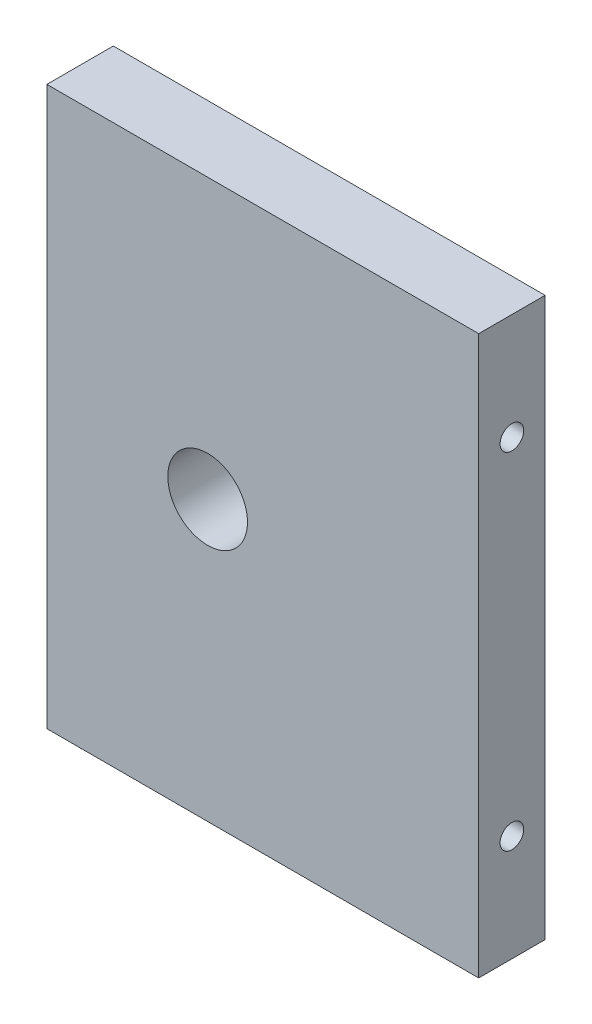
from build123d import *

# Parameters (mm, degrees)
SKETCH1_W                 = 32.5
SKETCH1_H                 = 42
BOSS_EXTRUDE2_DEPTH       = 5
F_2_56_TAPPED_HOLE1_D     = 1.778
F_2_56_TAPPED_HOLE1_DEPTH = 7.46583491
F_2_56_TAPPED_HOLE1_TIP   = 0.53416509
F_2_56_TAPPED_HOLE2_D     = 1.778
F_2_56_TAPPED_HOLE2_DEPTH = 7.46583491
F_2_56_TAPPED_HOLE2_TIP   = 0.53416509
CUT_EXTRUDE1_DEPTH        = 5


with BuildPart() as part:
    # Sketch1 → Boss-Extrude2 (new body)
    with BuildSketch(Plane.XY):
        with Locations((16.25, 21)):
            Rectangle(SKETCH1_W, SKETCH1_H)
    extrude(amount=BOSS_EXTRUDE2_DEPTH)

    # #2-56 Tapped Hole1
    with Locations(Plane.ZY):
        with Locations((2.5, 34), (2.5, 8)):
            Hole(F_2_56_TAPPED_HOLE1_D / 2, depth=F_2_56_TAPPED_HOLE1_DEPTH)
            with Locations((0, 0, -(F_2_56_TAPPED_HOLE1_DEPTH + F_2_56_TAPPED_HOLE1_TIP / 2))):  # 118° drill point
                Cone(0, F_2_56_TAPPED_HOLE1_D / 2, F_2_56_TAPPED_HOLE1_TIP, mode=Mode.SUBTRACT)

    # #2-56 Tapped Hole2
    with Locations(Plane(origin=(32.5, 0, 0), x_dir=(0, 0, -1), z_dir=(1, 0, 0))):
        with Locations((-2.5, 34), (-2.5, 8)):
            Hole(F_2_56_TAPPED_HOLE2_D / 2, depth=F_2_56_TAPPED_HOLE2_DEPTH)
            with Locations((0, 0, -(F_2_56_TAPPED_HOLE2_DEPTH + F_2_56_TAPPED_HOLE2_TIP / 2))):  # 118° drill point
                Cone(0, F_2_56_TAPPED_HOLE2_D / 2, F_2_56_TAPPED_HOLE2_TIP, mode=Mode.SUBTRACT)

    # Sketch9 → Cut-Extrude1 (cut)
    with BuildSketch(Plane(origin=(0, 0, 0), x_dir=(-1, 0, 0), z_dir=(0, 0, -1))):
        with BuildLine():
            ThreePointArc((-15.1, 21), (-12.1, 18), (-9.1, 21))
            Line((-9.1, 21), (-12.1, 21))
            Line((-12.1, 21), (-15.1, 21))
        make_face()
        with BuildLine():
            Line((-12.1, 21), (-9.1, 21))
            ThreePointArc((-9.1, 21), (-12.1, 24), (-15.1, 21))
            Line((-15.1, 21), (-12.1, 21))
        make_face()
    extrude(amount=-CUT_EXTRUDE1_DEPTH, mode=Mode.SUBTRACT)


solid = part.part
